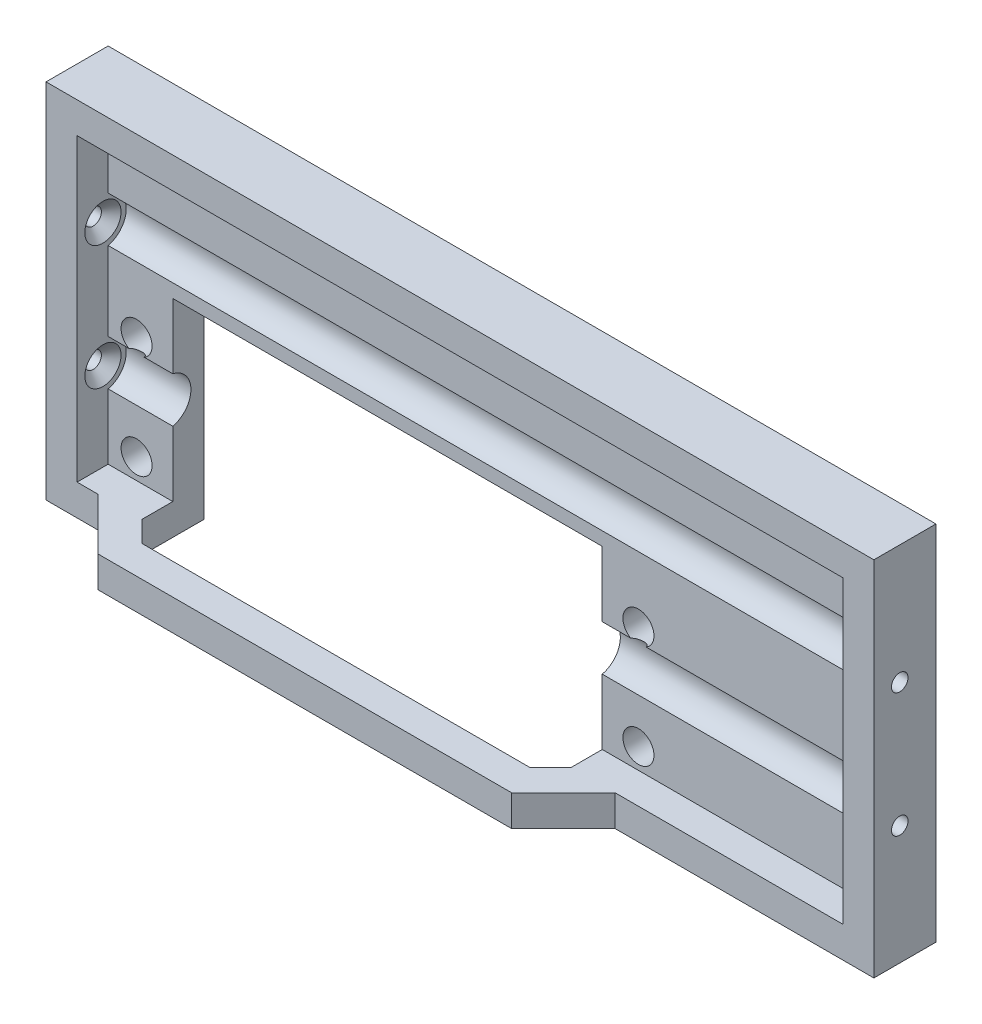
from build123d import *

# Parameters (mm, degrees)
AUFSATZ_LINEAR_AUSTRAGEN2_DEPTH             = 17.5
SKIZZE3_R                                   = 1.5
SKIZZE3_W                                   = 41.5
SKIZZE3_H                                   = 20
SCHNITT_LINEAR_AUSTRAGEN1_DEPTH             = 4
SKIZZE4_W                                   = 74
SKIZZE4_H                                   = 3
AUFSATZ_LINEAR_AUSTRAGEN3_DEPTH             = 3
AUFSATZ_LINEAR_AUSTRAGEN4_DEPTH             = 3
FORMSENKUNG_F_R_M3_SENKSCHRAUBE_MIT_2_COUNT = 2
FORMSENKUNG_F_R_M3_SENKSCHRAUBE_MIT_2_PITCH = 12
SKIZZE8_R                                   = 2.25
SCHNITT_LINEAR_AUSTRAGEN2_DEPTH             = 74


with BuildPart() as part:
    # Skizze2 → Aufsatz-Linear austragen2 (new body, symmetric)
    with BuildSketch(Plane(origin=(0, 0, 0), x_dir=(1, 0, 0), z_dir=(0, 1, 0))):
        Polygon((-40, 0), (40, 0), (40, -6), (37, -6), (37, -3), (-37, -3), (-37, -6), (-40, -6), align=None)
    extrude(amount=AUFSATZ_LINEAR_AUSTRAGEN2_DEPTH, both=True)

    # Skizze3 → Schnitt-Linear austragen1 (cut, through all)
    with BuildSketch(Plane.XY.offset(3)):
        with Locations((-34.25, -2.5)):
            Circle(SKIZZE3_R)
        with Locations((-34.25, -12.5)):
            Circle(SKIZZE3_R)
        with Locations((14.25, -2.5)):
            Circle(SKIZZE3_R)
        with Locations((14.25, -12.5)):
            Circle(SKIZZE3_R)
        with Locations((-10, -7.5)):
            Rectangle(SKIZZE3_W, SKIZZE3_H)
    extrude(amount=-SCHNITT_LINEAR_AUSTRAGEN1_DEPTH, mode=Mode.SUBTRACT)

    # Skizze4 → Aufsatz-Linear austragen3 (add)
    with BuildSketch(Plane.XY.offset(3)):
        with Locations((0, 16)):
            Rectangle(SKIZZE4_W, SKIZZE4_H)
    extrude(amount=AUFSATZ_LINEAR_AUSTRAGEN3_DEPTH)

    # Skizze5 → Aufsatz-Linear austragen4 (add)
    with BuildSketch(Plane.XZ.offset(17.5)):
        Polygon((-37, 6), (-34.992640687, 6), (-29.992640687, 11), (9.992640687, 11), (14.992640687, 6), (37, 6), (37, 3), (10.75, 3), (10.75, 6), (8.75, 8), (-28.75, 8), (-30.75, 6), (-30.75, 3), (-37, 3), align=None)
    extrude(amount=-AUFSATZ_LINEAR_AUSTRAGEN4_DEPTH)

    # Skizze6 → Formsenkung für M3 Senkschraube mit Innensechskant1 (revolve, cut)
    with BuildSketch(Plane(origin=(-37, 6, 3.5), x_dir=(0, 0, -1), z_dir=(0, 1, 0))):
        Polygon((0, 0), (0, 3), (0.8, 3), (0.8, 0.95), (1.75, 0), align=None)
    formsenkung_f_r_m3_senkschraube_mit_inne = revolve(axis=Axis((-30.65, 6, 3.5), (-1, 0, 0)), mode=Mode.SUBTRACT)

    # Formsenkung f_r M3 Senkschraube mit  2: Formsenkung für M3 Senkschraube mit Innensechskant1 ×2
    with Locations(*[(0, -i * FORMSENKUNG_F_R_M3_SENKSCHRAUBE_MIT_2_PITCH, 0) for i in range(1, FORMSENKUNG_F_R_M3_SENKSCHRAUBE_MIT_2_COUNT)]):
        add(formsenkung_f_r_m3_senkschraube_mit_inne, mode=Mode.SUBTRACT)

    # Skizze8 → Schnitt-Linear austragen2 (cut)
    with BuildSketch(Plane(origin=(-37, 0, 0), x_dir=(0, 0, -1), z_dir=(1, 0, 0))):
        with Locations((-3.5, -6)):
            Circle(SKIZZE8_R)
        with Locations((-3.5, 6)):
            Circle(SKIZZE8_R)
    extrude(amount=SCHNITT_LINEAR_AUSTRAGEN2_DEPTH, mode=Mode.SUBTRACT)

    # Spiegeln2: Formsenkung für M3 Senkschraube mit Innensechskant1 across plane
    add(formsenkung_f_r_m3_senkschraube_mit_inne.mirror(Plane(origin=(0, 0, 0), x_dir=(0, 0, 1), z_dir=(1, 0, 0))), mode=Mode.SUBTRACT)

    # Spiegeln2 copy 1 sketch → Spiegeln2 copy 1 (revolve, cut)
    with BuildSketch(Plane(origin=(37, -6, 3.5), x_dir=(0, 0, -1), z_dir=(0, 1, 0))):
        Polygon((0, 0), (0, -3), (0.8, -3), (0.8, -0.95), (1.75, 0), align=None)
    revolve(axis=Axis((30.65, -6, 3.5), (-1, 0, 0)), mode=Mode.SUBTRACT)


solid = part.part
